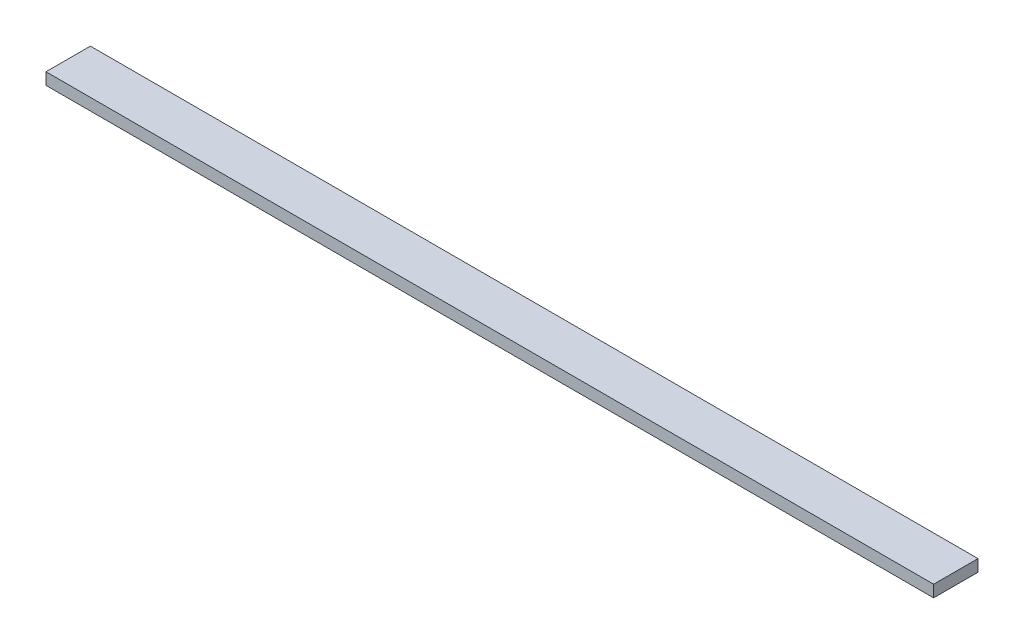
from build123d import *

# Parameters (mm, degrees)
SKETCH_1_W      = 600
SKETCH_1_H      = 30
EXTRUDE_1_DEPTH = 8


with BuildPart() as part:
    # Эскиз1 → Бобышка-Вытянуть1 (new body)
    with BuildSketch(Plane(origin=(0, 0, 0), x_dir=(1, 0, 0), z_dir=(0, 1, 0))):
        Rectangle(SKETCH_1_W, SKETCH_1_H)
    extrude(amount=EXTRUDE_1_DEPTH)


solid = part.part
